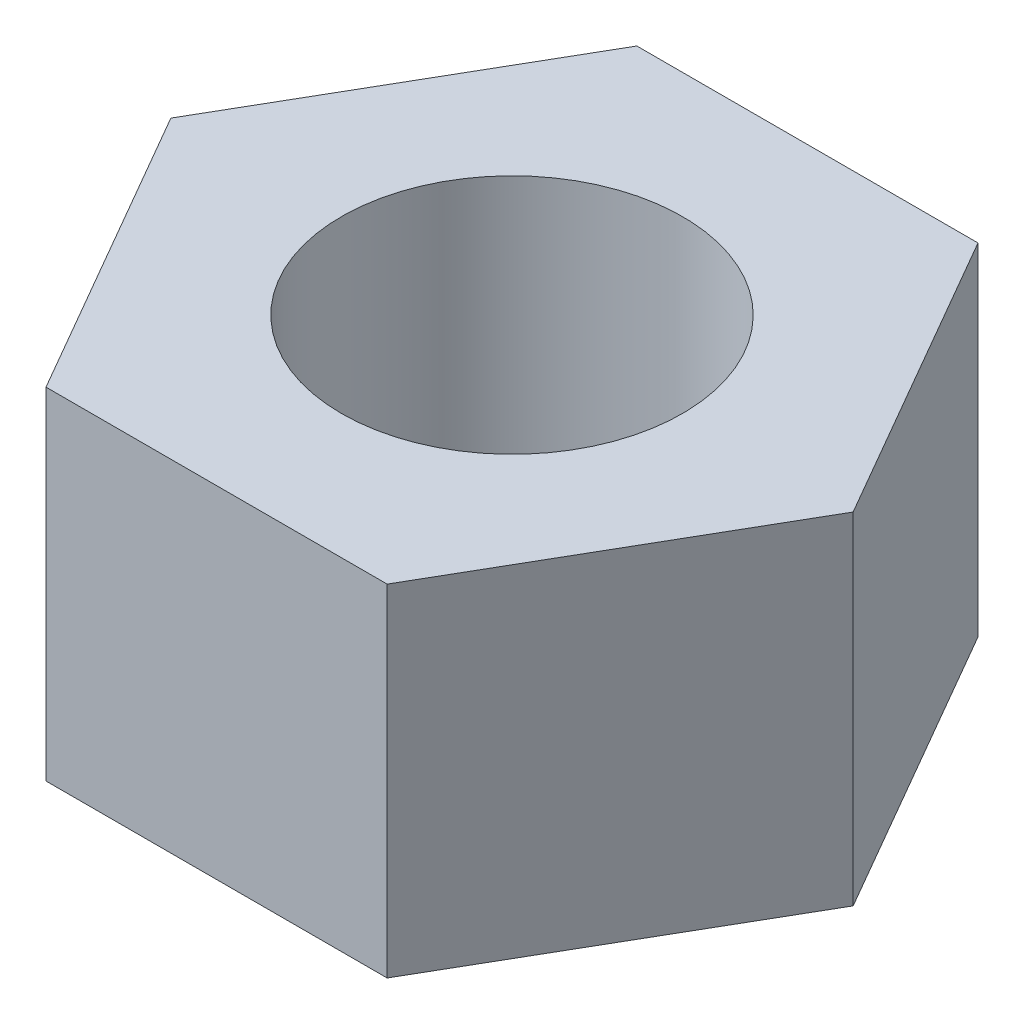
from build123d import *

# Parameters (mm, degrees)
SKETCH1_R           = 4.5
BOSS_EXTRUDE1_DEPTH = 4.5


with BuildPart() as part:
    # Sketch1 → Boss-Extrude1 (new body, symmetric)
    with BuildSketch(Plane(origin=(0, 0, 0), x_dir=(1, 0, 0), z_dir=(0, 1, 0))):
        Polygon((4.5, -7.794228634), (9, 0), (4.5, 7.794228634), (-4.5, 7.794228634), (-9, 0), (-4.5, -7.794228634), align=None)
        with Locations(Location((0, 0, 0), (0, 0, 270))):  # turned: the seam where the file's is
            Circle(SKETCH1_R, mode=Mode.SUBTRACT)
    extrude(amount=BOSS_EXTRUDE1_DEPTH, both=True)


solid = part.part
